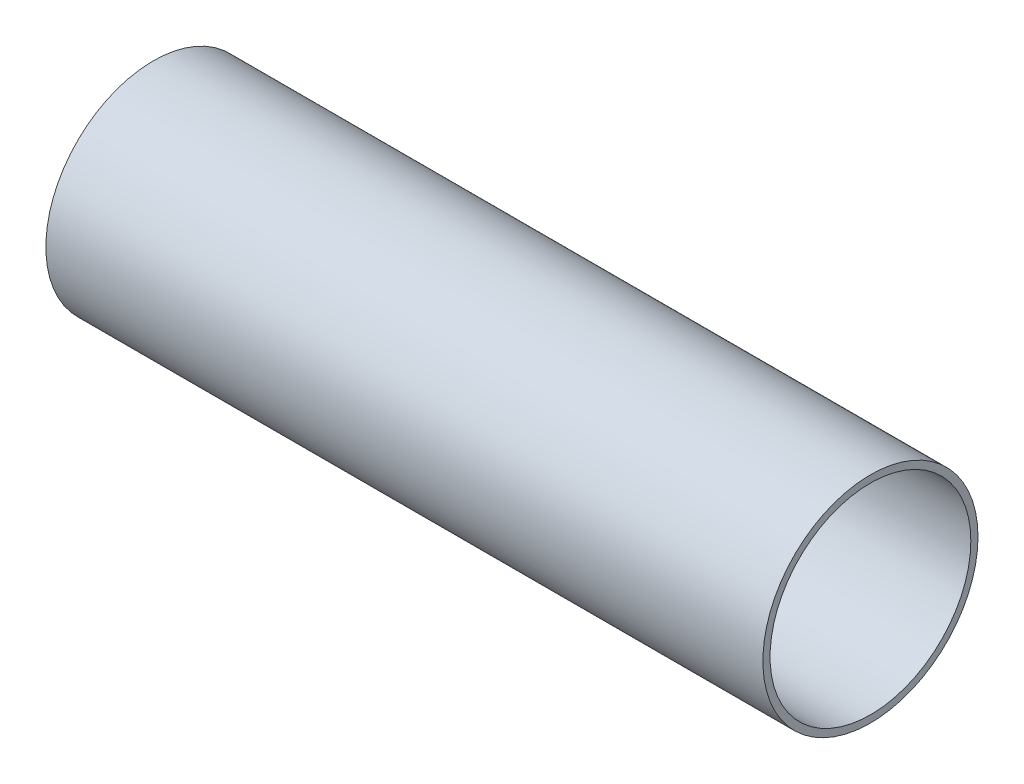
from build123d import *

# Parameters (mm, degrees)
SKETCH1_R           = 30
BOSS_EXTRUDE1_DEPTH = 200
SKETCH3_R           = 28
CUT_EXTRUDE1_DEPTH  = 200


with BuildPart() as part:
    # Sketch1 → Boss-Extrude1 (new body)
    with BuildSketch(Plane(origin=(0, 0, 0), x_dir=(0, 0, -1), z_dir=(1, 0, 0))):
        Circle(SKETCH1_R)
    extrude(amount=BOSS_EXTRUDE1_DEPTH)

    # Sketch3 → Cut-Extrude1 (cut)
    with BuildSketch(Plane(origin=(200, 0, 0), x_dir=(0, 0, -1), z_dir=(1, 0, 0))):
        Circle(SKETCH3_R)
    extrude(amount=-CUT_EXTRUDE1_DEPTH, mode=Mode.SUBTRACT)


solid = part.part
